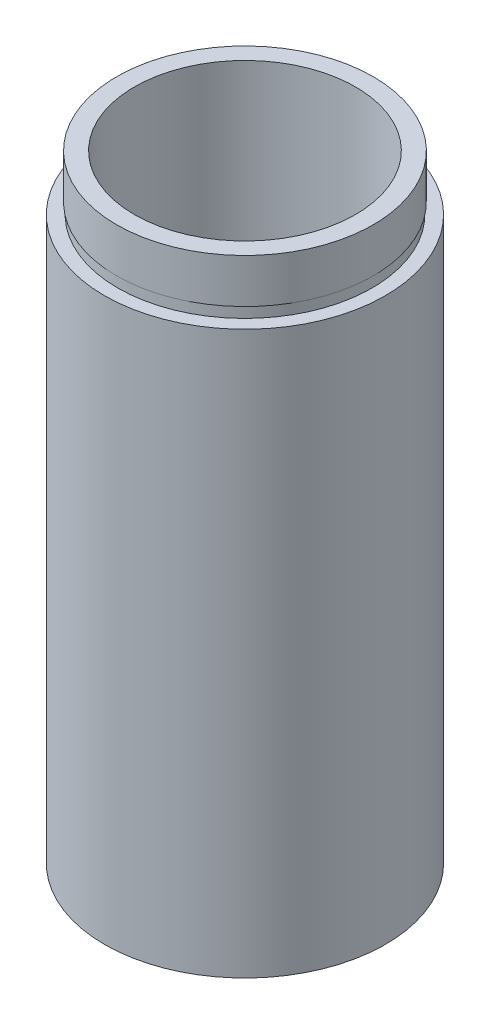
from build123d import *


with BuildPart() as part:
    # 草图1 → 旋转1 (revolve)
    with BuildSketch(Plane.XY, mode=Mode.PRIVATE) as revolve_1_sk:
        Polygon((12.7, 0), (12.7, 50.8), (11.5, 50.8), (11.5, 51.8), (11.6, 51.8), (11.6, 55.8), (10, 55.8), (10, 5.5), (11.7, 5.5), (11.7, 4.5), (11.1, 4.5), (11.1, 0), align=None)
    revolve(revolve_1_sk.sketch.rotate(Axis((0, 161.376166943, 0), (0, -1, 0)), 90), axis=Axis((0, 161.376166943, 0), (0, -1, 0)))  # turned: the seam where the file's is


solid = part.part
